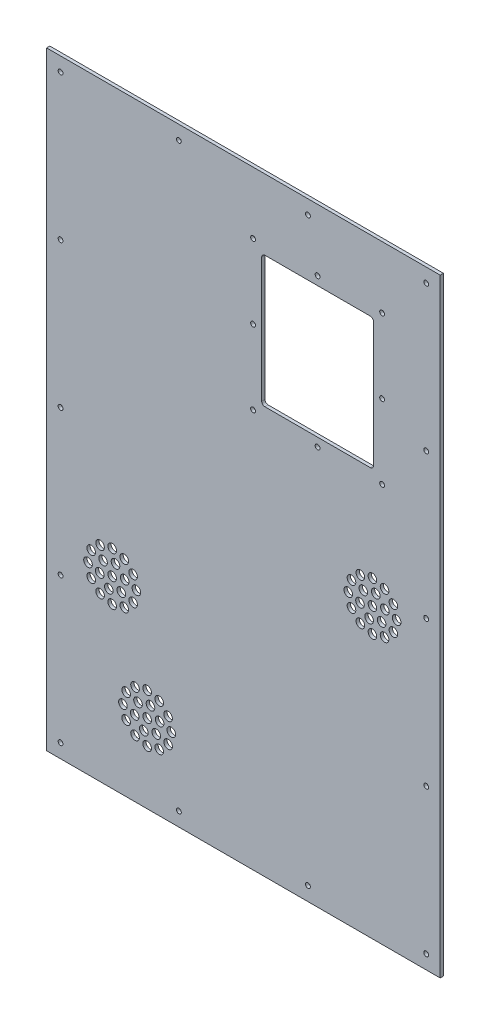
from build123d import *

# Parameters (mm, degrees)
SKETCH_1_W          = 366
SKETCH_1_H          = 566
EXTRUDE_1_DEPTH     = 3
SKETCH_5_R          = 2.25
CUT_EXTRUDE_2_DEPTH = 4
SKETCH_6_W          = 104
SKETCH_6_H          = 122
CUT_EXTRUDE_3_DEPTH = 4
SKETCH_7_R          = 2.25
CUT_EXTRUDE_4_DEPTH = 4
FILLET2_R           = 3
SKETCH_8_R          = 4
CUT_EXTRUDE_5_DEPTH = 4
SKETCH_9_R          = 4
CUT_EXTRUDE_6_DEPTH = 4


with BuildPart() as part:
    # Эскиз1 → Бобышка-Вытянуть1 (new body)
    with BuildSketch(Plane.XY):
        with Locations((183, 283)):
            Rectangle(SKETCH_1_W, SKETCH_1_H)
    extrude(amount=EXTRUDE_1_DEPTH)

    # Эскиз5 → Вырез-Вытянуть2 (cut, through all)
    with BuildSketch(Plane(origin=(0, 0, 0), x_dir=(-1, 0, 0), z_dir=(0, 0, -1))):
        with Locations((-353, 553)):
            Circle(SKETCH_5_R)
        with Locations((-13, 553)):
            Circle(SKETCH_5_R)
        with Locations((-243, 553)):
            Circle(SKETCH_5_R)
        with Locations((-123, 553)):
            Circle(SKETCH_5_R)
        with Locations((-353, 418)):
            Circle(SKETCH_5_R)
        with Locations((-353, 283)):
            Circle(SKETCH_5_R)
        with Locations((-353, 148)):
            Circle(SKETCH_5_R)
        with Locations((-353, 13)):
            Circle(SKETCH_5_R)
        with Locations((-13, 418)):
            Circle(SKETCH_5_R)
        with Locations((-13, 283)):
            Circle(SKETCH_5_R)
        with Locations((-13, 148)):
            Circle(SKETCH_5_R)
        with Locations((-13, 13)):
            Circle(SKETCH_5_R)
        with Locations((-123, 13)):
            Circle(SKETCH_5_R)
        with Locations((-243, 13)):
            Circle(SKETCH_5_R)
    extrude(amount=-CUT_EXTRUDE_2_DEPTH, mode=Mode.SUBTRACT)

    # Эскиз6 → Вырез-Вытянуть3 (cut, through all)
    with BuildSketch(Plane.XY.offset(3)):
        with Locations((252, 439.5)):
            Rectangle(SKETCH_6_W, SKETCH_6_H)
    extrude(amount=-CUT_EXTRUDE_3_DEPTH, mode=Mode.SUBTRACT)

    # Эскиз7 → Вырез-Вытянуть4 (cut, through all)
    with BuildSketch(Plane.XY.offset(3)):
        with Locations((192, 439.5)):
            Circle(SKETCH_7_R)
        with Locations((252, 508.5)):
            Circle(SKETCH_7_R)
        with Locations((312, 508.5)):
            Circle(SKETCH_7_R)
        with Locations((312, 439.5)):
            Circle(SKETCH_7_R)
        with Locations((312, 370.5)):
            Circle(SKETCH_7_R)
        with Locations((252, 370.5)):
            Circle(SKETCH_7_R)
        with Locations((192, 370.5)):
            Circle(SKETCH_7_R)
        with Locations((192, 508.5)):
            Circle(SKETCH_7_R)
    extrude(amount=-CUT_EXTRUDE_4_DEPTH, mode=Mode.SUBTRACT)

    # Fillet2
    fillet2_edges = [part.edges().sort_by_distance(p)[0] for p in [
        (304, 378.5, 1.5),
        (200, 378.5, 1.5),
        (200, 500.5, 1.5),
        (304, 500.5, 1.5),
    ]]
    fillet(fillet2_edges, radius=FILLET2_R)

    # Эскиз8 → Вырез-Вытянуть5 (cut, through all)
    with BuildSketch(Plane(origin=(0, 0, 0), x_dir=(-1, 0, 0), z_dir=(0, 0, -1))):
        with Locations((-61, 148.5)):
            Circle(SKETCH_8_R)
        with Locations((-69.485281374, 162.514718626)):
            Circle(SKETCH_8_R)
        with Locations((-61, 171)):
            Circle(SKETCH_8_R)
        with Locations((-72.25, 151.514428415)):
            Circle(SKETCH_8_R)
        with Locations((-80.485571585, 159.75)):
            Circle(SKETCH_8_R)
        with Locations((-83.5, 171)):
            Circle(SKETCH_8_R)
        with Locations((-80.485571585, 182.25)):
            Circle(SKETCH_8_R)
        with Locations((-72.25, 190.485571585)):
            Circle(SKETCH_8_R)
        with Locations((-61, 193.5)):
            Circle(SKETCH_8_R)
        with Locations((-49.75, 190.485571585)):
            Circle(SKETCH_8_R)
        with Locations((-41.514428415, 182.25)):
            Circle(SKETCH_8_R)
        with Locations((-38.5, 171)):
            Circle(SKETCH_8_R)
        with Locations((-41.514428415, 159.75)):
            Circle(SKETCH_8_R)
        with Locations((-49.75, 151.514428415)):
            Circle(SKETCH_8_R)
        with Locations((-72.591109915, 174.105828541)):
            Circle(SKETCH_8_R)
        with Locations((-64.105828541, 182.591109915)):
            Circle(SKETCH_8_R)
        with Locations((-52.514718626, 179.485281374)):
            Circle(SKETCH_8_R)
        with Locations((-49.408890085, 167.894171459)):
            Circle(SKETCH_8_R)
        with Locations((-57.894171459, 159.408890085)):
            Circle(SKETCH_8_R)
        with Locations((-93.5, 73)):
            Circle(SKETCH_8_R)
        with Locations((-93.5, 50.5)):
            Circle(SKETCH_8_R)
        with Locations((-101.985281374, 64.514718626)):
            Circle(SKETCH_8_R)
        with Locations((-104.75, 53.514428415)):
            Circle(SKETCH_8_R)
        with Locations((-112.985571585, 61.75)):
            Circle(SKETCH_8_R)
        with Locations((-116, 73)):
            Circle(SKETCH_8_R)
        with Locations((-112.985571585, 84.25)):
            Circle(SKETCH_8_R)
        with Locations((-104.75, 92.485571585)):
            Circle(SKETCH_8_R)
        with Locations((-93.5, 95.5)):
            Circle(SKETCH_8_R)
        with Locations((-82.25, 92.485571585)):
            Circle(SKETCH_8_R)
        with Locations((-74.014428415, 84.25)):
            Circle(SKETCH_8_R)
        with Locations((-71, 73)):
            Circle(SKETCH_8_R)
        with Locations((-74.014428415, 61.75)):
            Circle(SKETCH_8_R)
        with Locations((-82.25, 53.514428415)):
            Circle(SKETCH_8_R)
        with Locations((-105.091109915, 76.105828541)):
            Circle(SKETCH_8_R)
        with Locations((-96.605828541, 84.591109915)):
            Circle(SKETCH_8_R)
        with Locations((-85.014718626, 81.485281374)):
            Circle(SKETCH_8_R)
        with Locations((-81.908890085, 69.894171459)):
            Circle(SKETCH_8_R)
        with Locations((-90.394171459, 61.408890085)):
            Circle(SKETCH_8_R)
    extrude(amount=-CUT_EXTRUDE_5_DEPTH, mode=Mode.SUBTRACT)

    # Эскиз9 → Вырез-Вытянуть6 (cut, through all)
    with BuildSketch(Plane(origin=(0, 0, 0), x_dir=(-1, 0, 0), z_dir=(0, 0, -1))):
        with Locations((-303, 268)):
            Circle(SKETCH_9_R)
        with Locations((-303, 245.5)):
            Circle(SKETCH_9_R)
        with Locations((-311.485281374, 259.514718626)):
            Circle(SKETCH_9_R)
        with Locations((-314.25, 248.514428415)):
            Circle(SKETCH_9_R)
        with Locations((-322.485571585, 256.75)):
            Circle(SKETCH_9_R)
        with Locations((-325.5, 268)):
            Circle(SKETCH_9_R)
        with Locations((-322.485571585, 279.25)):
            Circle(SKETCH_9_R)
        with Locations((-314.25, 287.485571585)):
            Circle(SKETCH_9_R)
        with Locations((-303, 290.5)):
            Circle(SKETCH_9_R)
        with Locations((-291.75, 287.485571585)):
            Circle(SKETCH_9_R)
        with Locations((-283.514428415, 279.25)):
            Circle(SKETCH_9_R)
        with Locations((-280.5, 268)):
            Circle(SKETCH_9_R)
        with Locations((-283.514428415, 256.75)):
            Circle(SKETCH_9_R)
        with Locations((-291.75, 248.514428415)):
            Circle(SKETCH_9_R)
        with Locations((-314.591109915, 271.105828541)):
            Circle(SKETCH_9_R)
        with Locations((-306.105828541, 279.591109915)):
            Circle(SKETCH_9_R)
        with Locations((-294.514718626, 276.485281374)):
            Circle(SKETCH_9_R)
        with Locations((-291.408890085, 264.894171459)):
            Circle(SKETCH_9_R)
        with Locations((-299.894171459, 256.408890085)):
            Circle(SKETCH_9_R)
    extrude(amount=-CUT_EXTRUDE_6_DEPTH, mode=Mode.SUBTRACT)


solid = part.part
